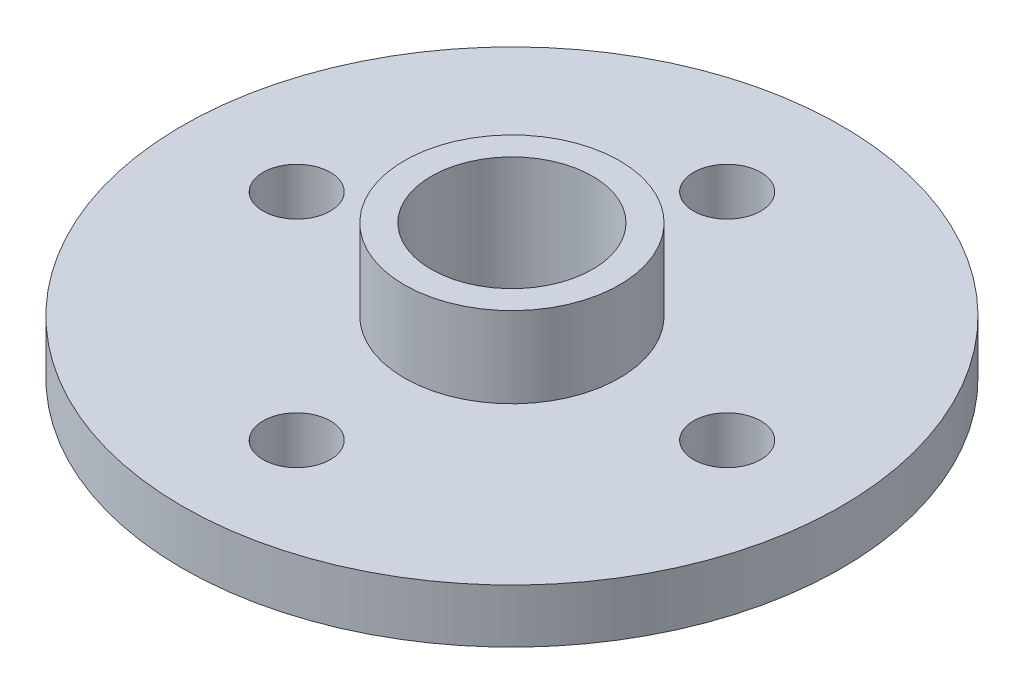
from build123d import *

# Parameters (mm, degrees)
SKETCH_1_R      = 12.25
SKETCH_1_R_2    = 3
SKETCH_1_R_3    = 1.25
EXTRUDE_1_DEPTH = 2
SKETCH_2_R      = 4
SKETCH_2_R_2    = 3
EXTRUDE_2_DEPTH = 3


with BuildPart() as part:
    # 草图1 → 凸台-拉伸1 (new body)
    with BuildSketch(Plane(origin=(0, 0, 0), x_dir=(1, 0, 0), z_dir=(0, 1, 0))):
        Circle(SKETCH_1_R)
        Circle(SKETCH_1_R_2, mode=Mode.SUBTRACT)
        with Locations((8, 0)):
            Circle(SKETCH_1_R_3, mode=Mode.SUBTRACT)
        with Locations((0, -8)):
            Circle(SKETCH_1_R_3, mode=Mode.SUBTRACT)
        with Locations((-8, 0)):
            Circle(SKETCH_1_R_3, mode=Mode.SUBTRACT)
        with Locations((0, 8)):
            Circle(SKETCH_1_R_3, mode=Mode.SUBTRACT)
    extrude(amount=EXTRUDE_1_DEPTH)

    # 草图2 → 凸台-拉伸2 (add)
    with BuildSketch(Plane(origin=(0, 2, 0), x_dir=(1, 0, 0), z_dir=(0, 1, 0))):
        Circle(SKETCH_2_R)
        Circle(SKETCH_2_R_2, mode=Mode.SUBTRACT)
    extrude(amount=EXTRUDE_2_DEPTH)


solid = part.part
